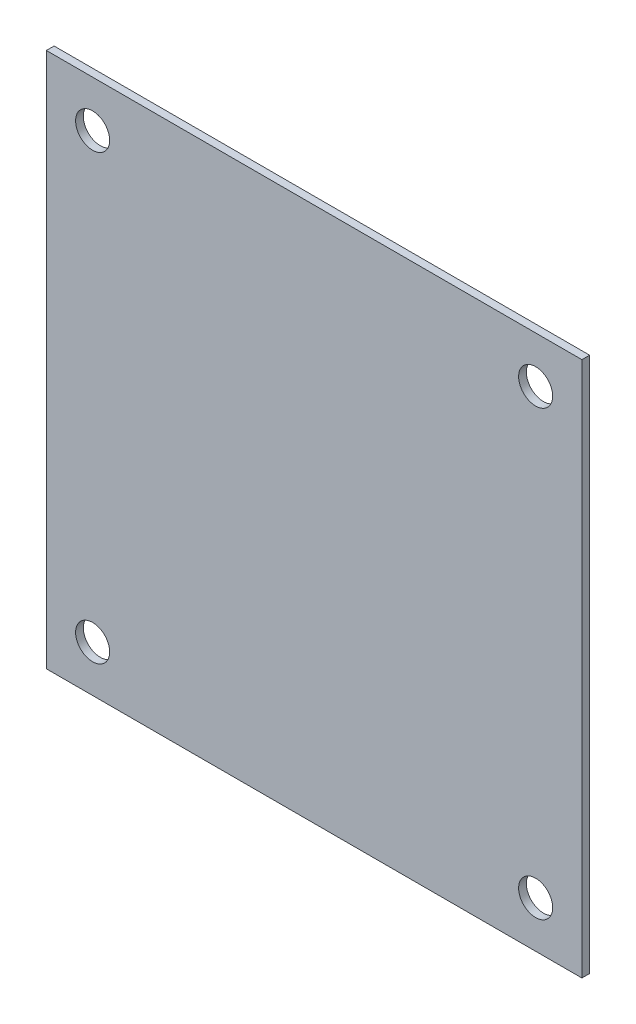
from build123d import *

# Parameters (mm, degrees)
MODEL_W             = 110
MODEL_H             = 110
MODEL_R             = 3.5
BOSS_EXTRUDE1_DEPTH = 1.5875


with BuildPart() as part:
    # Model → Boss-Extrude1 (new body)
    with BuildSketch(Plane.XY):
        with Locations((38.5, 38.5)):
            Rectangle(MODEL_W, MODEL_H)
        with Locations((84, 84)):
            Circle(MODEL_R, mode=Mode.SUBTRACT)
        with Locations((-7, 84)):
            Circle(MODEL_R, mode=Mode.SUBTRACT)
        with Locations((-7, -7)):
            Circle(MODEL_R, mode=Mode.SUBTRACT)
        with Locations((84, -7)):
            Circle(MODEL_R, mode=Mode.SUBTRACT)
    extrude(amount=BOSS_EXTRUDE1_DEPTH)


solid = part.part
